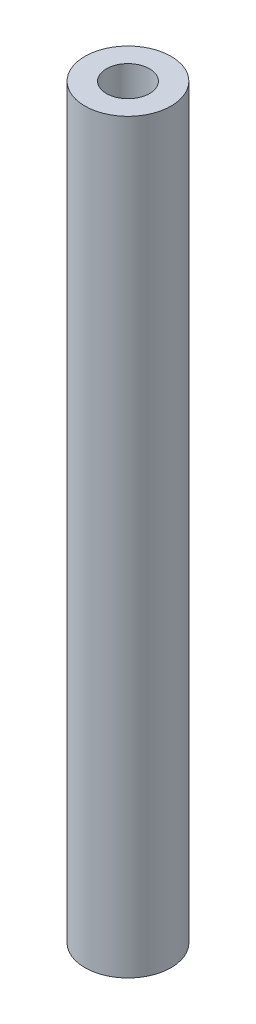
from build123d import *

# Parameters (mm, degrees)
SKETCH1_R           = 1.5875
SKETCH1_R_2         = 0.79375
BOSS_EXTRUDE1_DEPTH = 27.5


with BuildPart() as part:
    # Sketch1 → Boss-Extrude1 (new body)
    with BuildSketch(Plane(origin=(0, 0, 0), x_dir=(1, 0, 0), z_dir=(0, 1, 0))):
        Circle(SKETCH1_R)
        Circle(SKETCH1_R_2, mode=Mode.SUBTRACT)
    extrude(amount=BOSS_EXTRUDE1_DEPTH)


solid = part.part
